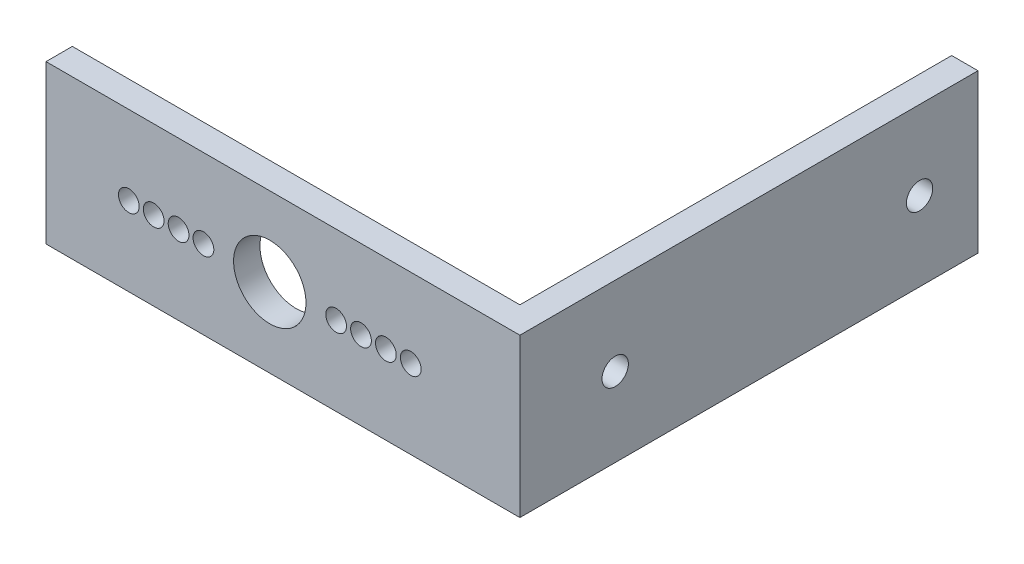
from build123d import *

# Parameters (mm, degrees)
SKETCH1_W           = 53.975
SKETCH1_H           = 19.05
SKETCH1_R           = 1.25
SKETCH1_R_2         = 4.365625
BOSS_EXTRUDE1_DEPTH = 3.175
SKETCH2_W           = 55.245
SKETCH2_H           = 19.05
SKETCH2_R           = 1.5875
BOSS_EXTRUDE2_DEPTH = 3.175


with BuildPart() as part:
    # Sketch1 → Boss-Extrude1 (new body)
    with BuildSketch(Plane.XY):
        with Locations((26.9875, 9.525)):
            Rectangle(SKETCH1_W, SKETCH1_H)
        with Locations((34.9875114, 9.525)):
            Circle(SKETCH1_R, mode=Mode.SUBTRACT)
        with Locations((43.9874934, 9.525)):
            Circle(SKETCH1_R, mode=Mode.SUBTRACT)
        with Locations((37.9875054, 9.525)):
            Circle(SKETCH1_R, mode=Mode.SUBTRACT)
        with Locations((40.9874994, 9.525)):
            Circle(SKETCH1_R, mode=Mode.SUBTRACT)
        with Locations((18.9874886, 9.525)):
            Circle(SKETCH1_R, mode=Mode.SUBTRACT)
        with Locations((15.9874946, 9.525)):
            Circle(SKETCH1_R, mode=Mode.SUBTRACT)
        with Locations((12.9875006, 9.525)):
            Circle(SKETCH1_R, mode=Mode.SUBTRACT)
        with Locations((9.9875066, 9.525)):
            Circle(SKETCH1_R, mode=Mode.SUBTRACT)
        with Locations((26.9875, 9.525)):
            Circle(SKETCH1_R_2, mode=Mode.SUBTRACT)
    extrude(amount=BOSS_EXTRUDE1_DEPTH)

    # Sketch2 → Boss-Extrude2 (add)
    with BuildSketch(Plane(origin=(53.975, 0, 0), x_dir=(0, 0, -1), z_dir=(1, 0, 0))):
        with Locations((24.4475, 9.525)):
            Rectangle(SKETCH2_W, SKETCH2_H)
        with Locations((8.3185, 9.525)):
            Circle(SKETCH2_R, mode=Mode.SUBTRACT)
        with Locations((45.0215, 9.525)):
            Circle(SKETCH2_R, mode=Mode.SUBTRACT)
    extrude(amount=BOSS_EXTRUDE2_DEPTH)


solid = part.part
